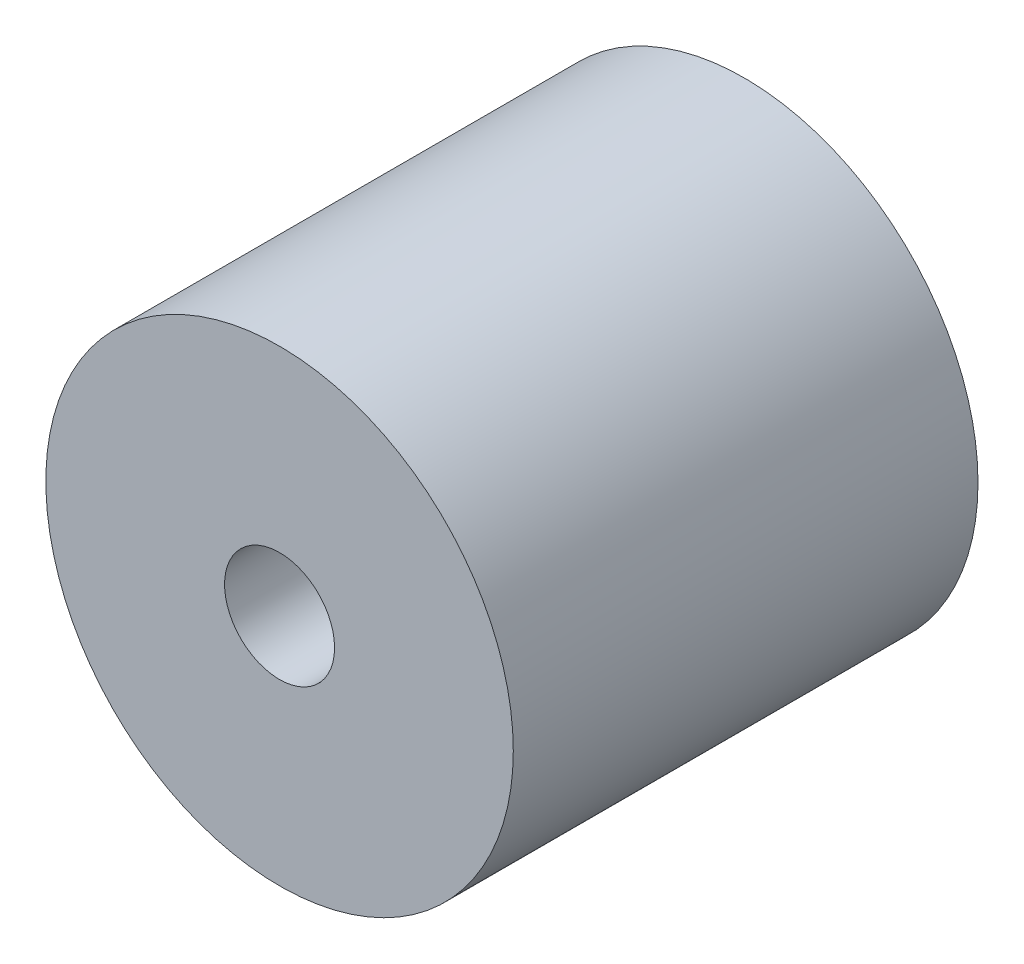
from build123d import *

# Parameters (mm, degrees)
SKETCH1_R           = 2.125
SKETCH1_R_2         = 0.5
BOSS_EXTRUDE1_DEPTH = 4.225


with BuildPart() as part:
    # Sketch1 → Boss-Extrude1 (new body)
    with BuildSketch(Plane.XY):
        Circle(SKETCH1_R)
        Circle(SKETCH1_R_2, mode=Mode.SUBTRACT)
    extrude(amount=BOSS_EXTRUDE1_DEPTH)


solid = part.part
